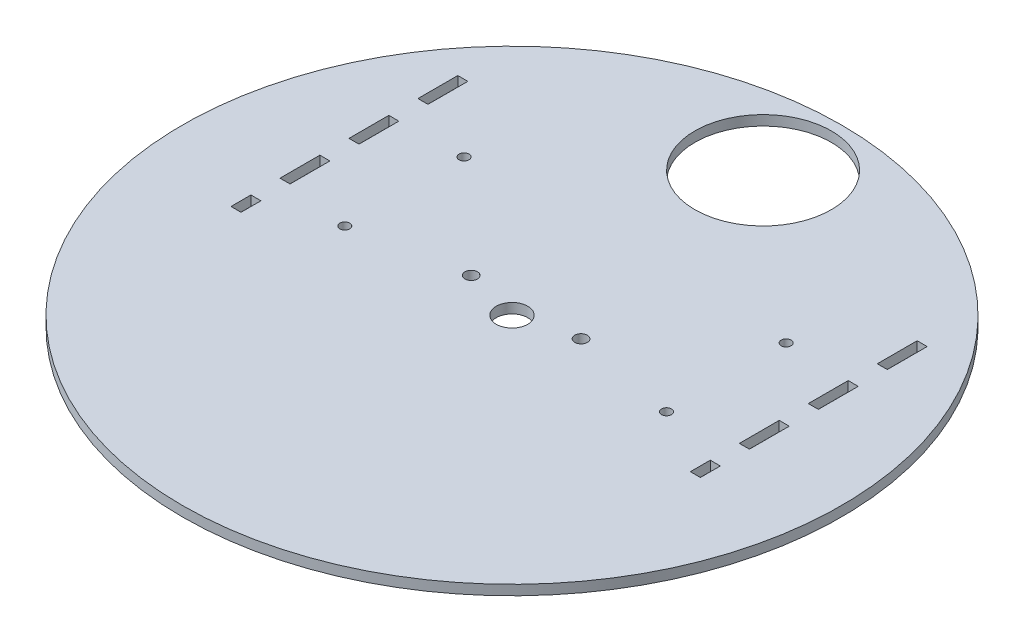
from build123d import *

# Parameters (mm, degrees)
SKETCH2_R           = 105
SKETCH2_R_2         = 21.75
SKETCH2_R_3         = 5
SKETCH2_R_4         = 2
BOSS_EXTRUDE2_DEPTH = 3.175
SKETCH8_W           = 3.2
SKETCH8_H           = 6.353
CUT_EXTRUDE1_DEPTH  = 4.175
SKETCH9_R           = 1.5875
CUT_EXTRUDE2_DEPTH  = 4.175


with BuildPart() as part:
    # Sketch2 → Boss-Extrude2 (new body)
    with BuildSketch(Plane(origin=(0, 0, 0), x_dir=(1, 0, 0), z_dir=(0, 1, 0))):
        Circle(SKETCH2_R)
        with Locations((0, 80)):
            Circle(SKETCH2_R_2, mode=Mode.SUBTRACT)
        Circle(SKETCH2_R_3, mode=Mode.SUBTRACT)
        with Locations((17.5, 4.5)):
            Circle(SKETCH2_R_4, mode=Mode.SUBTRACT)
        with Locations((-17.5, 4.5)):
            Circle(SKETCH2_R_4, mode=Mode.SUBTRACT)
    extrude(amount=BOSS_EXTRUDE2_DEPTH)

    # Sketch8 → Cut-Extrude1 (cut, through all)
    with BuildSketch(Plane(origin=(0, 3.175, 0), x_dir=(1, 0, 0), z_dir=(0, 1, 0))):
        Polygon((-74.777, 57.507097448), (-71.577, 57.507096503), (-71.577, 44.804096503), (-74.777, 44.804095482), align=None)
        with Locations((73.177, -11.5824036)):
            Rectangle(SKETCH8_W, SKETCH8_H)
        Polygon((-74.777, 35.536096628), (-71.577, 35.536096628), (-71.577, 22.833096628), (-74.777, 22.833096317), align=None)
        Polygon((-74.777, 13.565096577), (-71.577, 13.565096577), (-71.577, 0.862096577), (-74.777, 0.862095696), align=None)
        with Locations((-73.177, -11.5824036)):
            Rectangle(SKETCH8_W, SKETCH8_H)
        Polygon((71.577, 13.565096577), (71.577, 0.862096577), (74.777, 0.862095696), (74.777, 13.565096577), align=None)
        Polygon((71.577, 35.536096628), (71.577, 22.833096628), (74.777, 22.833096317), (74.777, 35.536096628), align=None)
        Polygon((71.577, 57.507096503), (71.577, 44.804096503), (74.777, 44.804095482), (74.777, 57.507097448), align=None)
    extrude(amount=-CUT_EXTRUDE1_DEPTH, mode=Mode.SUBTRACT)

    # Sketch9 → Cut-Extrude2 (cut, through all)
    with BuildSketch(Plane.XZ):
        with Locations((51.250084, 2.0166)):
            Circle(SKETCH9_R)
        with Locations((-51.315116, -36.0326)):
            Circle(SKETCH9_R)
        with Locations((-51.250084, 2.0166)):
            Circle(SKETCH9_R)
        with Locations((51.315116, -36.0326)):
            Circle(SKETCH9_R)
    extrude(amount=-CUT_EXTRUDE2_DEPTH, mode=Mode.SUBTRACT)


solid = part.part
